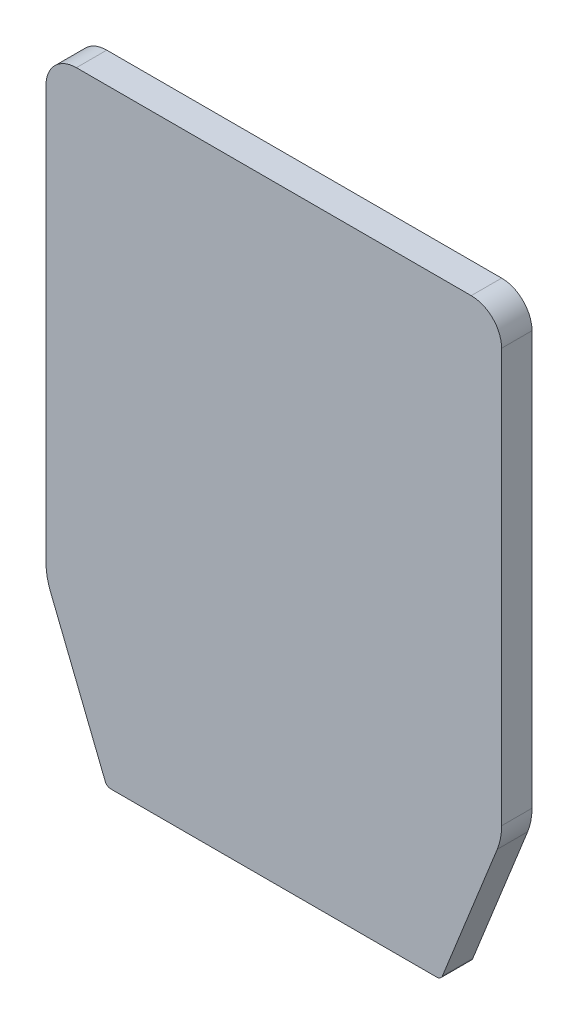
from build123d import *

# Parameters (mm, degrees)
BOSS_EXTRUDE1_DEPTH = 10


with BuildPart() as part:
    # Sketch-lid body → Boss-Extrude1 (new body)
    with BuildSketch(Plane.XY):
        with BuildLine():
            Line((55.502887459, 1.257218647), (73.569533818, 46.423834544))
            ThreePointArc((73.569533818, 46.423834544), (74.639127735, 50.069497648), (75, 53.851648071))
            Line((75, 53.851648071), (75, 190))
            ThreePointArc((75, 190), (72.071067812, 197.071067812), (65, 200))
            Line((65, 200), (-65, 200))
            ThreePointArc((-65, 200), (-72.071067812, 197.071067812), (-75, 190))
            Line((-75, 190), (-75, 53.851648071))
            ThreePointArc((-75, 53.851648071), (-74.639127735, 50.069497648), (-73.569533818, 46.423834544))
            Line((-73.569533818, 46.423834544), (-55.502887459, 1.257218647))
            ThreePointArc((-55.502887459, 1.257218647), (-54.767191696, 0.343865539), (-53.645934077, 0))
            Line((-53.645934077, 0), (53.645934077, 0))
            ThreePointArc((53.645934077, 0), (54.767191696, 0.343865539), (55.502887459, 1.257218647))
        make_face()
    extrude(amount=BOSS_EXTRUDE1_DEPTH)


solid = part.part
